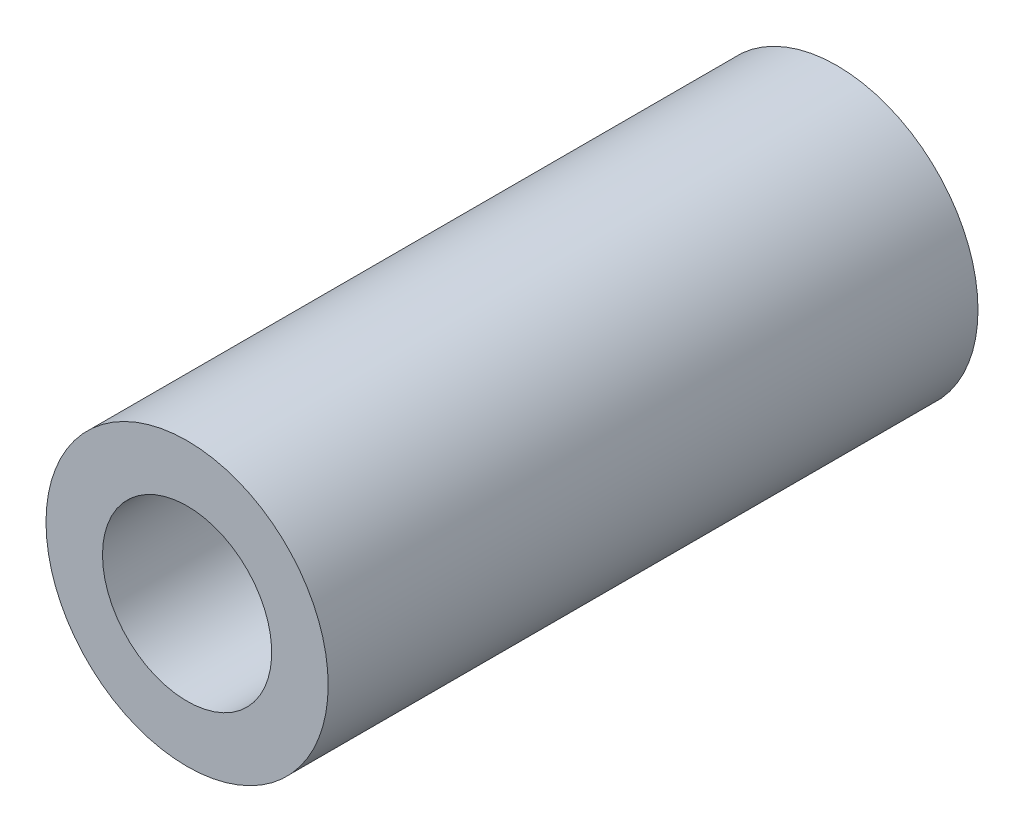
from build123d import *

# Parameters (mm, degrees)
SKETCH1_R           = 31.710080134
BOSS_EXTRUDE1_DEPTH = 146.05
SKETCH2_R           = 19.014013026
CUT_EXTRUDE1_DEPTH  = 146.05


with BuildPart() as part:
    # Sketch1 → Boss-Extrude1 (new body)
    with BuildSketch(Plane.XY):
        Circle(SKETCH1_R)
    extrude(amount=BOSS_EXTRUDE1_DEPTH)

    # Sketch2 → Cut-Extrude1 (cut)
    with BuildSketch(Plane(origin=(0, 0, 0), x_dir=(-1, 0, 0), z_dir=(0, 0, -1))):
        Circle(SKETCH2_R)
    extrude(amount=-CUT_EXTRUDE1_DEPTH, mode=Mode.SUBTRACT)


solid = part.part
